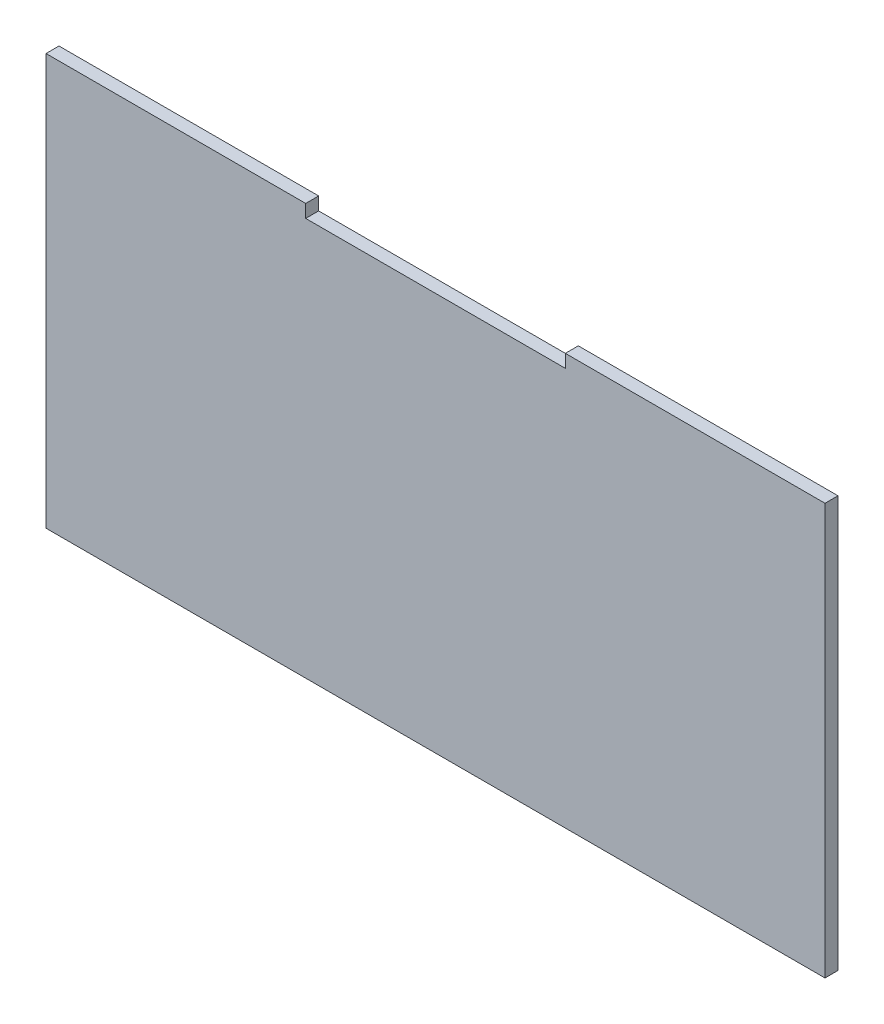
from build123d import *

# Parameters (mm, degrees)
BOSS_EXTRUDE1_DEPTH = 3


with BuildPart() as part:
    # Sketch1 → Boss-Extrude1 (new body)
    with BuildSketch(Plane.XY):
        Polygon((-30, 44.5), (30, 44.5), (30, 47.5), (90, 47.5), (90, -47.5), (-90, -47.5), (-90, 47.5), (-30, 47.5), align=None)
    extrude(amount=BOSS_EXTRUDE1_DEPTH)


solid = part.part
